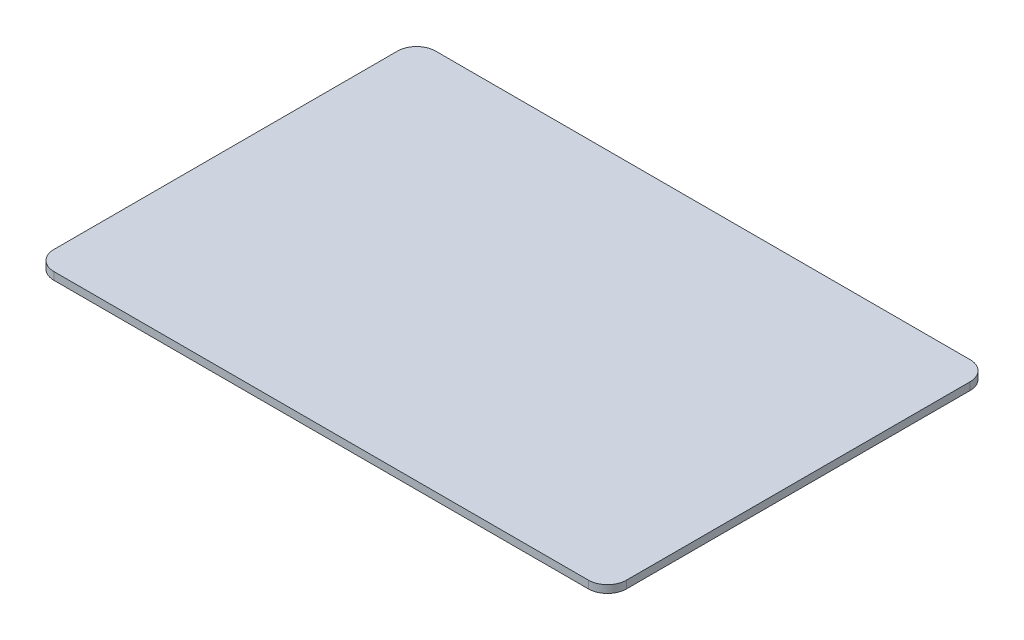
from build123d import *

# Parameters (mm, degrees)
BOSS_EXTRUDE1_DEPTH = 4


with BuildPart() as part:
    # Sketch1 → Boss-Extrude1 (new body)
    with BuildSketch(Plane(origin=(0, 0, 0), x_dir=(1, 0, 0), z_dir=(0, 1, 0))):
        with BuildLine():
            Line((140, -100), (-140, -100))
            ThreePointArc((-140, -100), (-147.071067812, -97.071067812), (-150, -90))
            Line((-150, -90), (-150, 90))
            ThreePointArc((-150, 90), (-147.071067812, 97.071067812), (-140, 100))
            Line((-140, 100), (140, 100))
            ThreePointArc((140, 100), (147.071067812, 97.071067812), (150, 90))
            Line((150, 90), (150, -90))
            ThreePointArc((150, -90), (147.071067812, -97.071067812), (140, -100))
        make_face()
    extrude(amount=BOSS_EXTRUDE1_DEPTH)


solid = part.part
